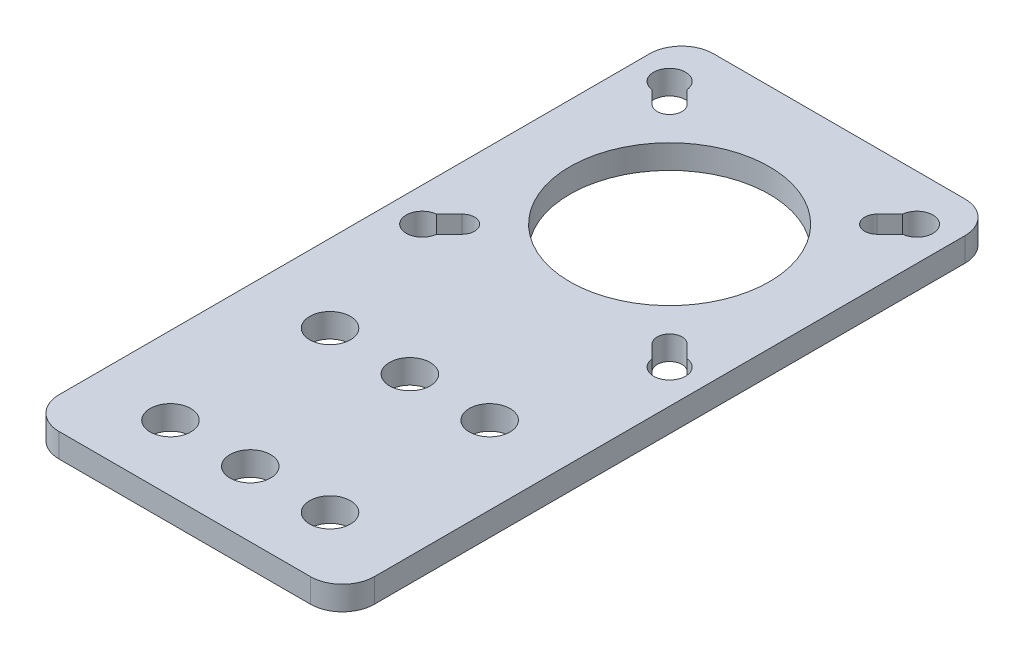
from build123d import *

# Parameters (mm, degrees)
SKETCH1_R           = 12.5
SKETCH1_R_2         = 2.55
BOSS_EXTRUDE1_DEPTH = 3
SKETCH2_R           = 2
CUT_EXTRUDE1_DEPTH  = 10


with BuildPart() as part:
    # Sketch1 → Boss-Extrude1 (new body)
    with BuildSketch(Plane(origin=(0, 0, 0), x_dir=(1, 0, 0), z_dir=(0, 1, 0))):
        with BuildLine():
            Line((15.75, -60.75), (-15.75, -60.75))
            ThreePointArc((-15.75, -60.75), (-18.578427125, -59.578427125), (-19.75, -56.75))
            Line((-19.75, -56.75), (-19.75, 17.25))
            ThreePointArc((-19.75, 17.25), (-18.578427125, 20.078427125), (-15.75, 21.25))
            Line((-15.75, 21.25), (15.75, 21.25))
            ThreePointArc((15.75, 21.25), (18.578427125, 20.078427125), (19.75, 17.25))
            Line((19.75, 17.25), (19.75, -56.75))
            ThreePointArc((19.75, -56.75), (18.578427125, -59.578427125), (15.75, -60.75))
        make_face()
        Circle(SKETCH1_R, mode=Mode.SUBTRACT)
        with Locations((10, -52.55)):
            Circle(SKETCH1_R_2, mode=Mode.SUBTRACT)
        with Locations((10, -32.55)):
            Circle(SKETCH1_R_2, mode=Mode.SUBTRACT)
        with Locations((0, -52.55)):
            Circle(SKETCH1_R_2, mode=Mode.SUBTRACT)
        with Locations((0, -32.55)):
            Circle(SKETCH1_R_2, mode=Mode.SUBTRACT)
        with Locations((-10, -52.55)):
            Circle(SKETCH1_R_2, mode=Mode.SUBTRACT)
        with Locations((-10, -32.55)):
            Circle(SKETCH1_R_2, mode=Mode.SUBTRACT)
        with BuildLine():
            Line((11.903984489, 14.096015511), (14.403984489, 16.596015511))
            ThreePointArc((14.403984489, 16.596015511), (16.596015511, 16.596015511), (16.596015511, 14.403984489))
            Line((16.596015511, 14.403984489), (14.096015511, 11.903984489))
            ThreePointArc((14.096015511, 11.903984489), (11.903984489, 11.903984489), (11.903984489, 14.096015511))
        make_face(mode=Mode.SUBTRACT)
        with BuildLine():
            Line((-11.903984489, 14.096015511), (-14.403984489, 16.596015511))
            ThreePointArc((-14.403984489, 16.596015511), (-16.596015511, 16.596015511), (-16.596015511, 14.403984489))
            Line((-16.596015511, 14.403984489), (-14.096015511, 11.903984489))
            ThreePointArc((-14.096015511, 11.903984489), (-11.903984489, 11.903984489), (-11.903984489, 14.096015511))
        make_face(mode=Mode.SUBTRACT)
        with BuildLine():
            Line((-11.903984489, -14.096015511), (-14.403984489, -16.596015511))
            ThreePointArc((-14.403984489, -16.596015511), (-16.596015511, -16.596015511), (-16.596015511, -14.403984489))
            Line((-16.596015511, -14.403984489), (-14.096015511, -11.903984489))
            ThreePointArc((-14.096015511, -11.903984489), (-11.903984489, -11.903984489), (-11.903984489, -14.096015511))
        make_face(mode=Mode.SUBTRACT)
        with BuildLine():
            Line((11.903984489, -14.096015511), (14.403984489, -16.596015511))
            ThreePointArc((14.403984489, -16.596015511), (16.596015511, -16.596015511), (16.596015511, -14.403984489))
            Line((16.596015511, -14.403984489), (14.096015511, -11.903984489))
            ThreePointArc((14.096015511, -11.903984489), (11.903984489, -11.903984489), (11.903984489, -14.096015511))
        make_face(mode=Mode.SUBTRACT)
    extrude(amount=BOSS_EXTRUDE1_DEPTH)

    # Sketch2 → Cut-Extrude1 (cut)
    with BuildSketch(Plane(origin=(0, 3, 0), x_dir=(1, 0, 0), z_dir=(0, 1, 0))):
        with Locations((-15.5, 15.5)):
            Circle(SKETCH2_R)
        with Locations((15.5, 15.5)):
            Circle(SKETCH2_R)
        with Locations((-15.5, -15.5)):
            Circle(SKETCH2_R)
        with Locations((15.5, -15.5)):
            Circle(SKETCH2_R)
    extrude(amount=-CUT_EXTRUDE1_DEPTH, mode=Mode.SUBTRACT)


solid = part.part
